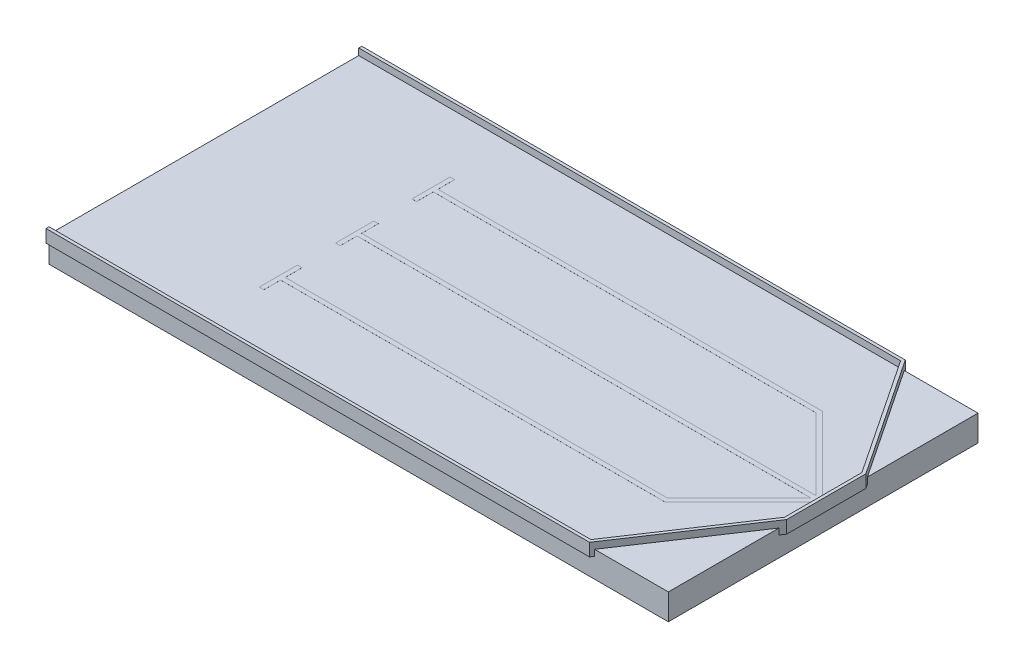
from build123d import *

# Parameters (mm, degrees)
SKETCH1_W                = 2438.4
SKETCH1_H                = 1219.2
BOSS_EXTRUDE1_DEPTH      = 102
EXTRUDE_THIN1_DEPTH      = 26
EXTRUDE_THIN1_DEPTH_BACK = 24
BOSS_EXTRUDE2_DEPTH      = 0.17


with BuildPart() as part:
    # Sketch1 → Boss-Extrude1 (new body)
    with BuildSketch(Plane(origin=(0, 0, 0), x_dir=(1, 0, 0), z_dir=(0, 1, 0))):
        with Locations((1219.2, 609.6)):
            Rectangle(SKETCH1_W, SKETCH1_H)
    extrude(amount=BOSS_EXTRUDE1_DEPTH)

    # Sketch2 → Extrude-Thin1 (add, two sides)
    with BuildSketch(Plane(origin=(0, 102, 0), x_dir=(1, 0, 0), z_dir=(0, 1, 0))) as extrude_thin1_sk:
        Polygon((0, 0), (2133.6, 0), (2438.4, 457.2), (2438.4, 762), (2133.6, 1219.2), (0, 1219.2), (0, 1231.2), (2140.022205102, 1231.2), (2450.4, 765.633307653), (2450.4, 453.566692347), (2140.022205102, -12), (0, -12), align=None)
    extrude(amount=EXTRUDE_THIN1_DEPTH)
    extrude(extrude_thin1_sk.sketch, amount=-EXTRUDE_THIN1_DEPTH_BACK)

    # Sketch3 → Boss-Extrude2 (add)
    with BuildSketch(Plane(origin=(0, 102, 0), x_dir=(1, 0, 0), z_dir=(0, 1, 0))):
        Polygon((2400.4, 618.6), (611.985938124, 618.6), (611.985938124, 684.6), (593.985938124, 684.6), (593.985938124, 534.6), (611.985938124, 534.6), (611.985938124, 600.6), (2400.4, 600.6), (2117.8, 318), (611.985938124, 318), (611.985938124, 384), (593.985938124, 384), (593.985938124, 234), (611.985938124, 234), (611.985938124, 300), (2125.255844123, 300), (2418.4, 593.144155877), (2418.4, 626.055844123), (2125.255844123, 919.2), (611.985938124, 919.2), (611.985938124, 985.2), (593.985938124, 985.2), (593.985938124, 835.2), (611.985938124, 835.2), (611.985938124, 901.2), (2117.8, 901.2), align=None)
    extrude(amount=BOSS_EXTRUDE2_DEPTH)


solid = part.part
